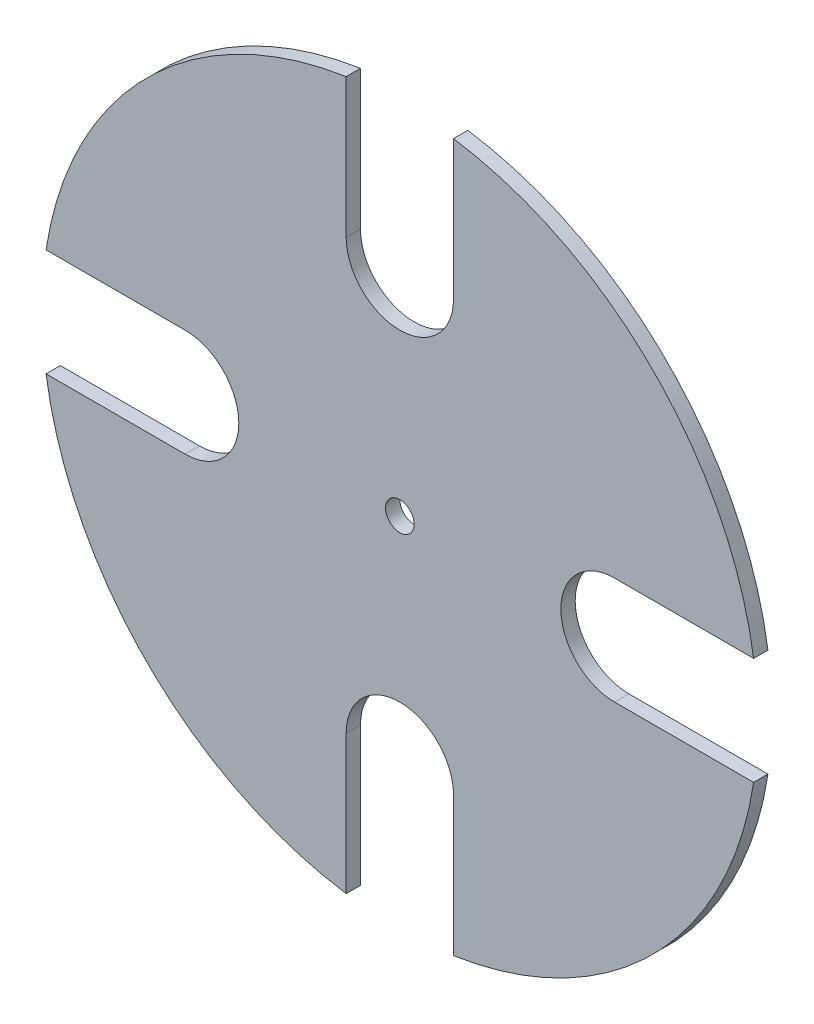
from build123d import *

# Parameters (mm, degrees)
SKETCH1_R           = 100
SKETCH1_R_2         = 4
BOSS_EXTRUDE1_DEPTH = 4
CUT_EXTRUDE2_START  = -4
CUT_EXTRUDE2_DEPTH  = 5
CIRPATTERN14_COUNT  = 4


with BuildPart() as part:
    # Sketch1 → Boss-Extrude1 (new body)
    with BuildSketch(Plane.XY):
        Circle(SKETCH1_R)
        Circle(SKETCH1_R_2, mode=Mode.SUBTRACT)
    extrude(amount=BOSS_EXTRUDE1_DEPTH)

    # Sketch2 → Cut-Extrude2 (cut)
    with BuildSketch(Plane.XY.offset(4).offset(CUT_EXTRUDE2_START)):
        with BuildLine():
            Line((-15, 682.376448842), (-15, 134.079674161))
            Line((-15, 134.079674161), (-15, 60))
            ThreePointArc((-15, 60), (0, 45), (15, 60))
            Line((15, 60), (15, 143.343079639))
            Line((15, 143.343079639), (15, 691.63985432))
            Line((15, 691.63985432), (-308.533757453, 1739.42004133))
            Line((-308.533757453, 1739.42004133), (-338.533757453, 1730.156635852))
            Line((-338.533757453, 1730.156635852), (-15, 682.376448842))
        make_face()
    cut_extrude2 = extrude(amount=CUT_EXTRUDE2_DEPTH, mode=Mode.SUBTRACT)

    # CirPattern14: Cut-Extrude2 ×4 about axis
    cirpattern14_axis = Axis((0, 0, 0), (0, 0, 1))
    for i in range(1, CIRPATTERN14_COUNT):
        add(cut_extrude2.rotate(cirpattern14_axis, i * 360 / CIRPATTERN14_COUNT), mode=Mode.SUBTRACT)


solid = part.part
